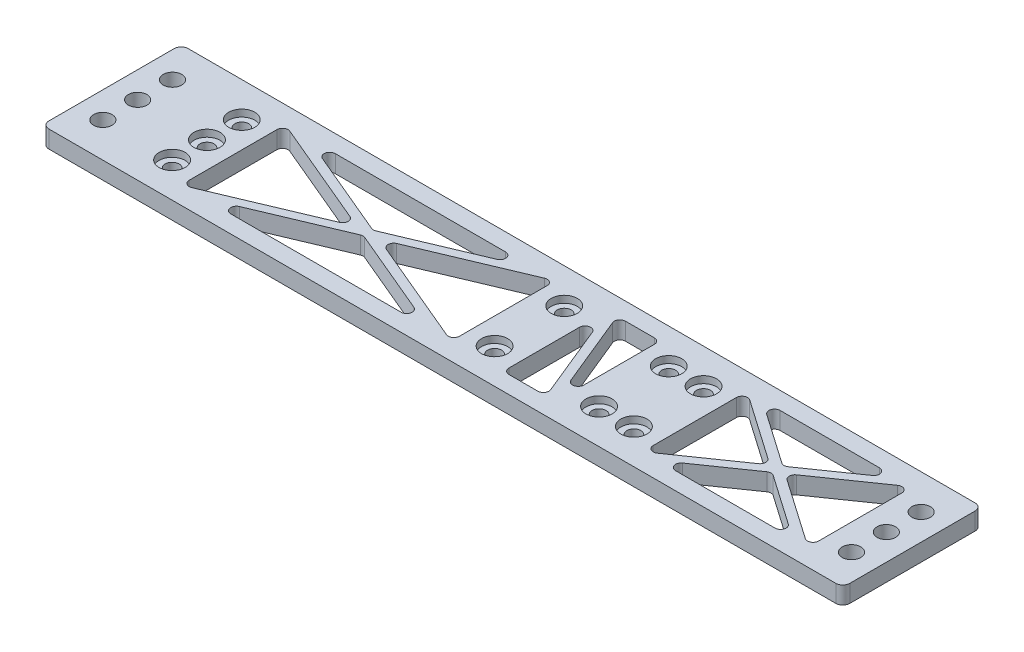
from build123d import *

# Parameters (mm, degrees)
SKETCH1_W                                       = 292.1
SKETCH1_H                                       = 50.8
BOSS_EXTRUDE1_DEPTH                             = 6.35
CBORE_FOR_10_SOCKET_HEAD_CAP_SCREW1_D           = 5.1054
CBORE_FOR_10_SOCKET_HEAD_CAP_SCREW1_CBORE_D     = 9.525
CBORE_FOR_10_SOCKET_HEAD_CAP_SCREW1_CBORE_DEPTH = 2.54
F_1_4_CLEARANCE_HOLE1_D                         = 6.7564
FILLET1_R                                       = 2.54
CUT_EXTRUDE1_DEPTH                              = 7.35


with BuildPart() as part:
    # Sketch1 → Boss-Extrude1 (new body)
    with BuildSketch(Plane(origin=(0, 0, 0), x_dir=(1, 0, 0), z_dir=(0, 1, 0))):
        Rectangle(SKETCH1_W, SKETCH1_H)
    extrude(amount=BOSS_EXTRUDE1_DEPTH)

    # CBORE for #10 Socket Head Cap Screw1 (through all)
    with Locations(Plane(origin=(0, 6.35, 0), x_dir=(1, 0, 0), z_dir=(0, 1, 0))):
        with Locations((44.45, 12.7), (6.35, 12.7), (6.35, -12.7), (44.45, -12.7), (-111.252, 12.7), (-111.252, 0), (-111.252, -12.7), (57.15, 12.7), (57.15, -12.7)):
            CounterBoreHole(CBORE_FOR_10_SOCKET_HEAD_CAP_SCREW1_D / 2, CBORE_FOR_10_SOCKET_HEAD_CAP_SCREW1_CBORE_D / 2, CBORE_FOR_10_SOCKET_HEAD_CAP_SCREW1_CBORE_DEPTH)

    # 1/4 Clearance Hole1 (through all)
    with Locations(Plane.XZ):
        with Locations((-136.525, 12.7), (-136.525, 0), (-136.525, -12.7), (136.525, 12.7), (136.525, 0), (136.525, -12.7)):
            Hole(F_1_4_CLEARANCE_HOLE1_D / 2)

    # Fillet1
    fillet1_edges = [part.edges().sort_by_distance(p)[0] for p in [
        (146.05, 3.175, 25.4),
        (-146.05, 3.175, 25.4),
        (-146.05, 3.175, -25.4),
        (146.05, 3.175, -25.4),
    ]]
    fillet(fillet1_edges, radius=FILLET1_R)

    # Sketch8 → Cut-Extrude1 (cut, through all)
    with BuildSketch(Plane.XZ):
        with BuildLine():
            Line((-83.502395687, -19.05), (-21.399604313, -19.05))
            ThreePointArc((-21.399604313, -19.05), (-19.407898045, -17.420653874), (-20.61026549, -15.145576911))
            Line((-20.61026549, -15.145576911), (-51.661661177, -2.055548129))
            ThreePointArc((-51.661661177, -2.055548129), (-52.451, -1.895971218), (-53.240338823, -2.055548129))
            Line((-53.240338823, -2.055548129), (-84.29173451, -15.145576911))
            ThreePointArc((-84.29173451, -15.145576911), (-85.494101955, -17.420653874), (-83.502395687, -19.05))
        make_face()
        with BuildLine():
            Line((-101.727, -15.988213098), (-101.727, 15.988213098))
            ThreePointArc((-101.727, 15.988213098), (-100.818629724, 17.681281391), (-98.905661177, 17.860636186))
            Line((-98.905661177, 17.860636186), (-60.979363267, 1.872423089))
            ThreePointArc((-60.979363267, 1.872423089), (-59.73670209, 0), (-60.979363267, -1.872423089))
            Line((-60.979363267, -1.872423089), (-98.905661177, -17.860636186))
            ThreePointArc((-98.905661177, -17.860636186), (-100.818629724, -17.681281391), (-101.727, -15.988213098))
        make_face()
        with BuildLine():
            Line((-83.502395687, 19.05), (-21.399604313, 19.05))
            ThreePointArc((-21.399604313, 19.05), (-19.407898045, 17.420653874), (-20.61026549, 15.145576911))
            Line((-20.61026549, 15.145576911), (-51.661661177, 2.055548129))
            ThreePointArc((-51.661661177, 2.055548129), (-52.451, 1.895971218), (-53.240338823, 2.055548129))
            Line((-53.240338823, 2.055548129), (-84.29173451, 15.145576911))
            ThreePointArc((-84.29173451, 15.145576911), (-85.494101955, 17.420653874), (-83.502395687, 19.05))
        make_face()
        with BuildLine():
            Line((-3.175, -15.988213098), (-3.175, 15.988213098))
            ThreePointArc((-3.175, 15.988213098), (-4.083370276, 17.681281391), (-5.996338823, 17.860636186))
            Line((-5.996338823, 17.860636186), (-43.922636733, 1.872423089))
            ThreePointArc((-43.922636733, 1.872423089), (-45.16529791, 0), (-43.922636733, -1.872423089))
            Line((-43.922636733, -1.872423089), (-5.996338823, -17.860636186))
            ThreePointArc((-5.996338823, -17.860636186), (-4.083370276, -17.681281391), (-3.175, -15.988213098))
        make_face()
        with BuildLine():
            Line((20.455368131, -16.247256429), (31.012846191, 9.506682143))
            ThreePointArc((31.012846191, 9.506682143), (33.285779492, 10.729615644), (34.925, 8.735938572))
            Line((34.925, 8.735938572), (34.925, -17.018))
            ThreePointArc((34.925, -17.018), (34.329840979, -18.454840979), (32.893, -19.05))
            Line((32.893, -19.05), (22.33552194, -19.05))
            ThreePointArc((22.33552194, -19.05), (20.64804232, -18.150005535), (20.455368131, -16.247256429))
        make_face()
        with BuildLine():
            Line((15.875, -8.735938572), (15.875, 17.018))
            ThreePointArc((15.875, 17.018), (16.470159021, 18.454840979), (17.907, 19.05))
            Line((17.907, 19.05), (28.46447806, 19.05))
            ThreePointArc((28.46447806, 19.05), (30.15195768, 18.150005535), (30.344631869, 16.247256429))
            Line((30.344631869, 16.247256429), (19.787153809, -9.506682143))
            ThreePointArc((19.787153809, -9.506682143), (17.514220508, -10.729615644), (15.875, -8.735938572))
        make_face()
        with BuildLine():
            Line((78.713510728, -19.05), (114.961489272, -19.05))
            ThreePointArc((114.961489272, -19.05), (116.900367087, -17.626092773), (116.121939653, -15.349953564))
            Line((116.121939653, -15.349953564), (97.997950381, -2.741197719))
            ThreePointArc((97.997950381, -2.741197719), (96.8375, -2.377244155), (95.677049619, -2.741197719))
            Line((95.677049619, -2.741197719), (77.553060347, -15.349953564))
            ThreePointArc((77.553060347, -15.349953564), (76.774632913, -17.626092773), (78.713510728, -19.05))
        make_face()
        with BuildLine():
            Line((66.675, -15.160984063), (66.675, 15.160984063))
            ThreePointArc((66.675, 15.160984063), (67.765992873, 16.961964237), (69.867450381, 16.8290305))
            Line((69.867450381, 16.8290305), (91.660045614, 1.668046436))
            ThreePointArc((91.660045614, 1.668046436), (92.531595233, 0), (91.660045614, -1.668046436))
            Line((91.660045614, -1.668046436), (69.867450381, -16.8290305))
            ThreePointArc((69.867450381, -16.8290305), (67.765992873, -16.961964237), (66.675, -15.160984063))
        make_face()
        with BuildLine():
            Line((78.713510728, 19.05), (114.961489272, 19.05))
            ThreePointArc((114.961489272, 19.05), (116.900367087, 17.626092773), (116.121939653, 15.349953564))
            Line((116.121939653, 15.349953564), (97.997950381, 2.741197719))
            ThreePointArc((97.997950381, 2.741197719), (96.8375, 2.377244155), (95.677049619, 2.741197719))
            Line((95.677049619, 2.741197719), (77.553060347, 15.349953564))
            ThreePointArc((77.553060347, 15.349953564), (76.774632913, 17.626092773), (78.713510728, 19.05))
        make_face()
        with BuildLine():
            Line((127, -15.160984063), (127, 15.160984063))
            ThreePointArc((127, 15.160984063), (125.909007127, 16.961964237), (123.807549619, 16.8290305))
            Line((123.807549619, 16.8290305), (102.014954386, 1.668046436))
            ThreePointArc((102.014954386, 1.668046436), (101.143404767, 0), (102.014954386, -1.668046436))
            Line((102.014954386, -1.668046436), (123.807549619, -16.8290305))
            ThreePointArc((123.807549619, -16.8290305), (125.909007127, -16.961964237), (127, -15.160984063))
        make_face()
    extrude(amount=-CUT_EXTRUDE1_DEPTH, mode=Mode.SUBTRACT)


solid = part.part
